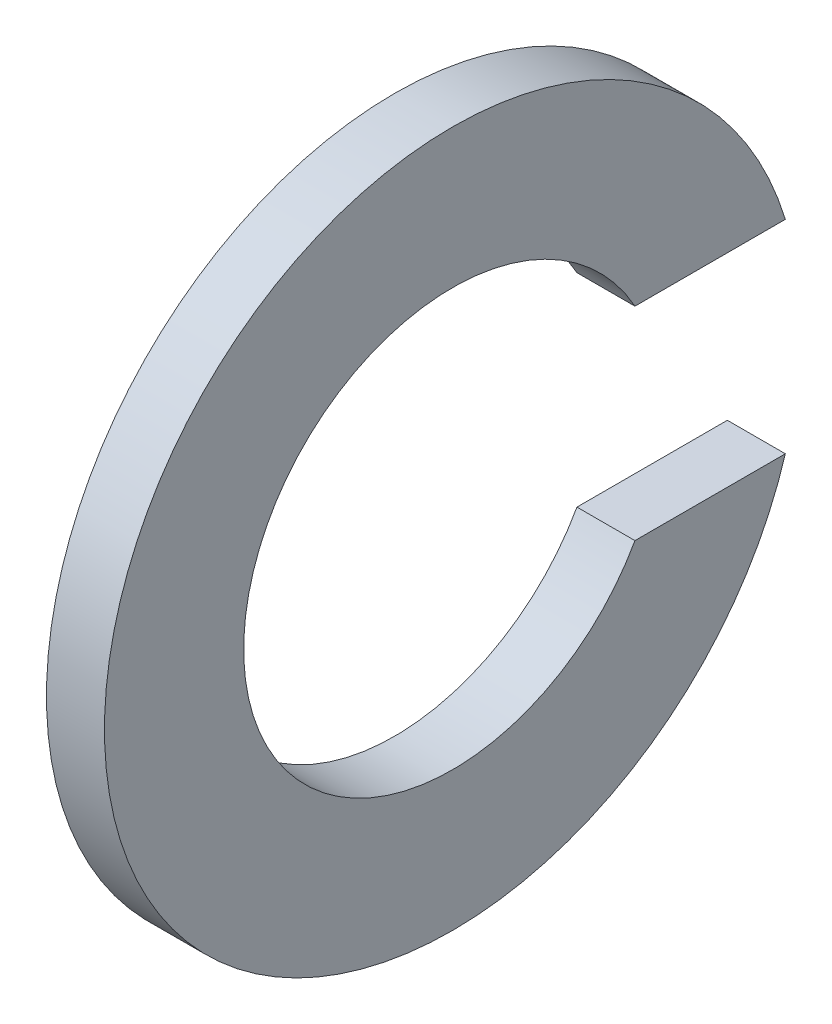
from build123d import *

# Parameters (mm, degrees)
BOSS_EXTRUDE1_DEPTH = 0.5


with BuildPart() as part:
    # Sketch1 → Boss-Extrude1 (new body, symmetric)
    with BuildSketch(Plane(origin=(0, 0, 0), x_dir=(0, 0, -1), z_dir=(1, 0, 0))):
        with BuildLine():
            Line((3.146029243, 1.75), (5.739120142, 1.75))
            ThreePointArc((5.739120142, 1.75), (-6, 0), (5.739120142, -1.75))
            Line((5.739120142, -1.75), (3.146029243, -1.75))
            ThreePointArc((3.146029243, -1.75), (-3.6, 0), (3.146029243, 1.75))
        make_face()
    extrude(amount=BOSS_EXTRUDE1_DEPTH, both=True)


solid = part.part
